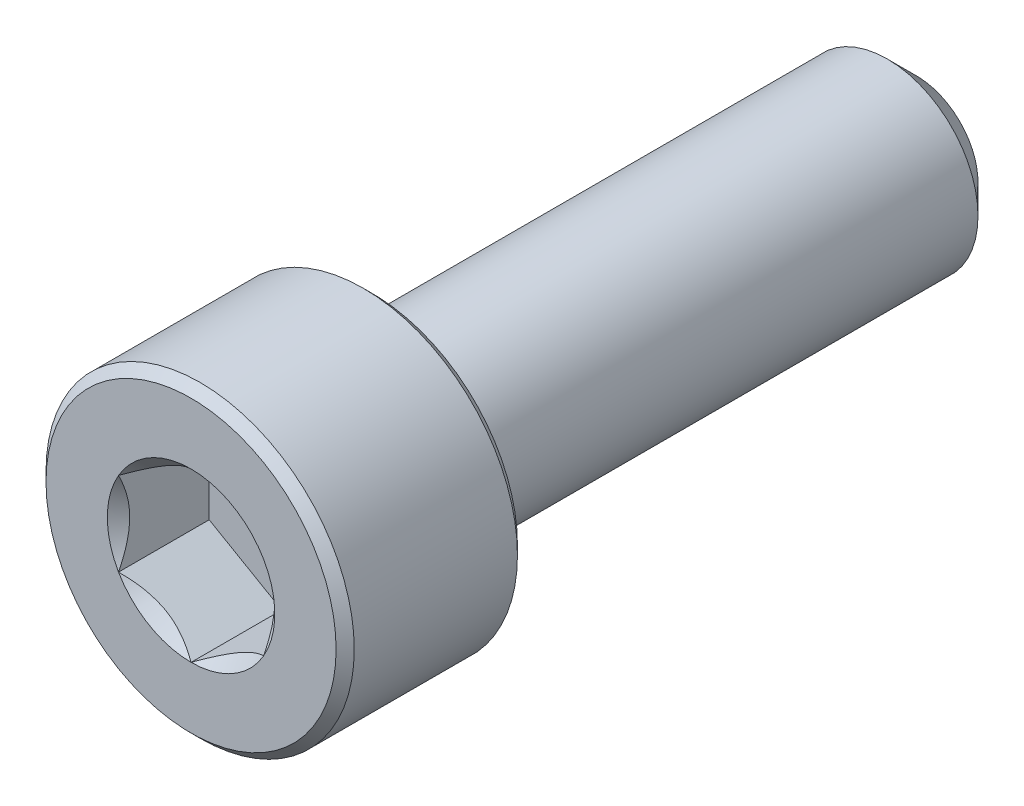
from build123d import *

# Parameters (mm, degrees)
CUT_EXTRUDE1_START = -2.5
CUT_EXTRUDE1_DEPTH = 2.5
SKETCH4_R          = 2.309401077
CUT_EXTRUDE2_DEPTH = 0.5
CUT_EXTRUDE2_TAPER = 45


with BuildPart() as part:
    # Sketch2 → Revolve1 (revolve)
    with BuildSketch(Plane(origin=(0, 0, 0), x_dir=(0, 0, -1), z_dir=(1, 0, 0))):
        Polygon((-9.75, 4.25), (-5.25, 4.25), (-5, 4), (-5, 2.5), (9.2, 2.5), (10, 1.7), (10, 0), (-10, 0), (-10, 4), align=None)
    revolve(axis=Axis((0, 0, -10), (0, 0, 1)))

    # Sketch3 → Cut-Extrude1 (cut)
    with BuildSketch(Plane.XY.offset(10).offset(CUT_EXTRUDE1_START)):
        Polygon((0, 2.309401077), (-2, 1.154700538), (-2, -1.154700538), (0, -2.309401077), (2, -1.154700538), (2, 1.154700538), align=None)
    extrude(amount=CUT_EXTRUDE1_DEPTH, mode=Mode.SUBTRACT)

    # Sketch4 → Cut-Extrude2 (cut)
    with BuildSketch(Plane.XY.offset(10)):
        Circle(SKETCH4_R)
    extrude(amount=-CUT_EXTRUDE2_DEPTH, taper=CUT_EXTRUDE2_TAPER, mode=Mode.SUBTRACT)


solid = part.part
